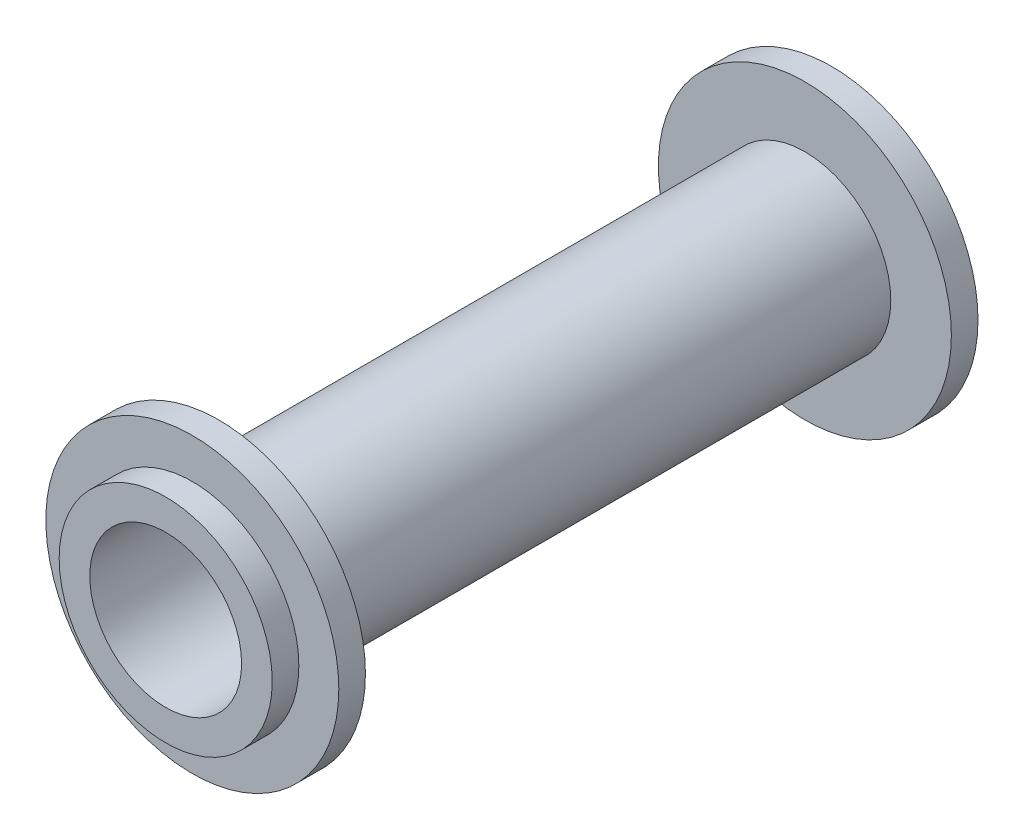
from build123d import *

# Parameters (mm, degrees)
SKETCH1_R           = 8
BOSS_EXTRUDE1_DEPTH = 2
SKETCH2_R           = 11
BOSS_EXTRUDE2_DEPTH = 2
SKETCH3_R           = 6.45
BOSS_EXTRUDE3_DEPTH = 44
SKETCH4_R           = 11
BOSS_EXTRUDE4_DEPTH = 2
SKETCH5_R           = 8
BOSS_EXTRUDE5_DEPTH = 2
SKETCH6_R           = 5.7
CUT_EXTRUDE1_DEPTH  = 53


with BuildPart() as part:
    # Sketch1 → Boss-Extrude1 (new body)
    with BuildSketch(Plane.XY):
        Circle(SKETCH1_R)
    extrude(amount=BOSS_EXTRUDE1_DEPTH)

    # Sketch2 → Boss-Extrude2 (add)
    with BuildSketch(Plane.XY.offset(2)):
        Circle(SKETCH2_R)
    extrude(amount=BOSS_EXTRUDE2_DEPTH)

    # Sketch3 → Boss-Extrude3 (add)
    with BuildSketch(Plane.XY.offset(4)):
        Circle(SKETCH3_R)
    extrude(amount=BOSS_EXTRUDE3_DEPTH)

    # Sketch4 → Boss-Extrude4 (add)
    with BuildSketch(Plane.XY.offset(48)):
        Circle(SKETCH4_R)
    extrude(amount=BOSS_EXTRUDE4_DEPTH)

    # Sketch5 → Boss-Extrude5 (add)
    with BuildSketch(Plane.XY.offset(50)):
        Circle(SKETCH5_R)
    extrude(amount=BOSS_EXTRUDE5_DEPTH)

    # Sketch6 → Cut-Extrude1 (cut, through all)
    with BuildSketch(Plane.XY.offset(52)):
        Circle(SKETCH6_R)
    extrude(amount=-CUT_EXTRUDE1_DEPTH, mode=Mode.SUBTRACT)


solid = part.part
